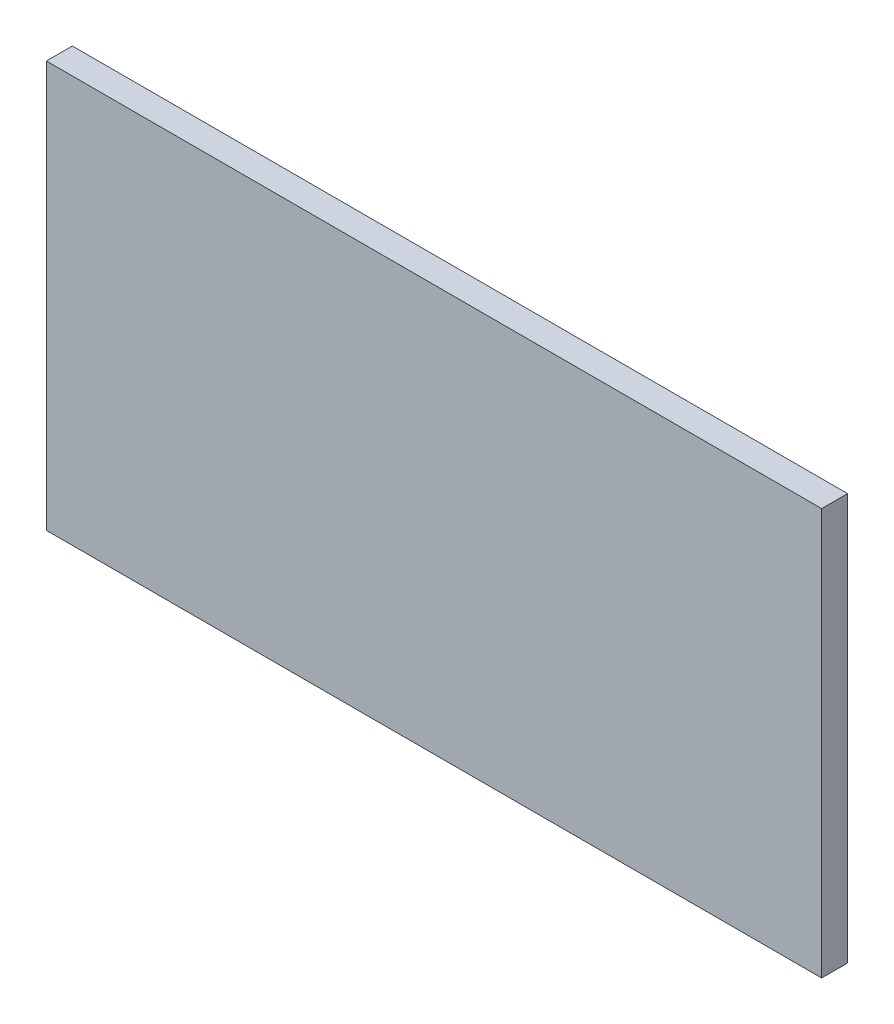
from build123d import *

# Parameters (mm, degrees)
SKETCH1_W           = 179.270792672
SKETCH1_H           = 93.999121706
BOSS_EXTRUDE1_DEPTH = 6


with BuildPart() as part:
    # Sketch1 → Boss-Extrude1 (new body)
    with BuildSketch(Plane.XY):
        Rectangle(SKETCH1_W, SKETCH1_H)
    extrude(amount=-BOSS_EXTRUDE1_DEPTH)


solid = part.part
